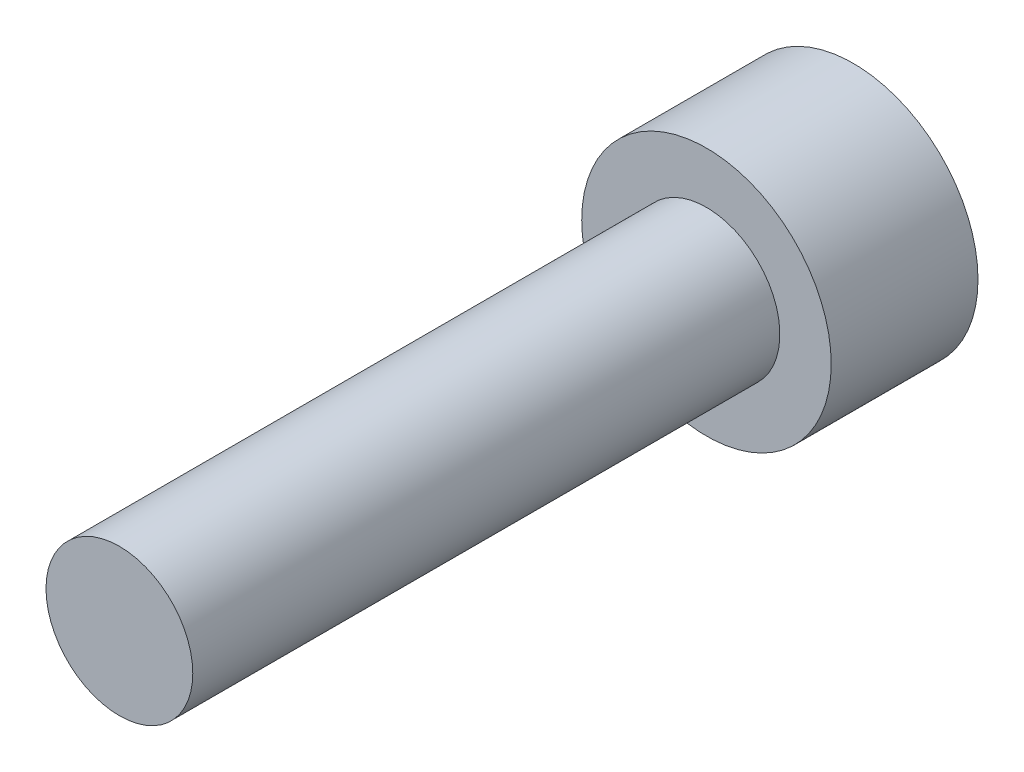
from build123d import *

# Parameters (mm, degrees)
CROQUIS1_R              = 2.5
SALIENTE_EXTRUIR1_DEPTH = 20
CROQUIS2_R              = 4.25
SALIENTE_EXTRUIR2_DEPTH = 5
CORTAR_EXTRUIR1_DEPTH   = 2.5


with BuildPart() as part:
    # Croquis1 → Saliente-Extruir1 (new body)
    with BuildSketch(Plane.XY):
        Circle(CROQUIS1_R)
    extrude(amount=SALIENTE_EXTRUIR1_DEPTH)

    # Croquis2 → Saliente-Extruir2 (add)
    with BuildSketch(Plane(origin=(0, 0, 0), x_dir=(-1, 0, 0), z_dir=(0, 0, -1))):
        Circle(CROQUIS2_R)
    extrude(amount=SALIENTE_EXTRUIR2_DEPTH)

    # Croquis3 → Cortar-Extruir1 (cut)
    with BuildSketch(Plane(origin=(0, 0, -5), x_dir=(-1, 0, 0), z_dir=(0, 0, -1))):
        Polygon((1.267478326, 1.93050046), (-1.038123277, 2.062918659), (-2.305601603, 0.132418199), (-1.267478326, -1.93050046), (1.038123277, -2.062918659), (2.305601603, -0.132418199), align=None)
    extrude(amount=-CORTAR_EXTRUIR1_DEPTH, mode=Mode.SUBTRACT)


solid = part.part
